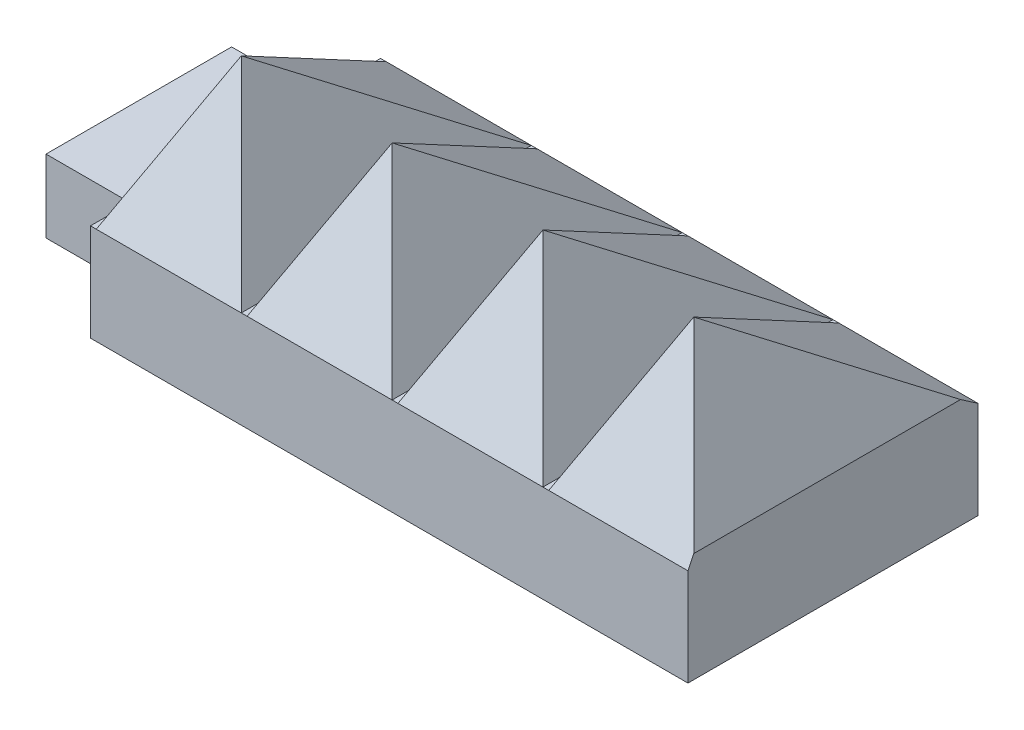
from build123d import *

# Parameters (mm, degrees)
SKETCH1_W           = 19.05
SKETCH1_H           = 19.05
BOSS_EXTRUDE2_DEPTH = 6.35
SKETCH8_W           = 217.17
SKETCH8_H           = 38.1
BOSS_EXTRUDE4_DEPTH = 6.35
SKETCH8_5_W         = 217.17
SKETCH8_5_H         = 38.1
BOSS_EXTRUDE5_DEPTH = 6.4262
SKETCH9_W           = 19.05
SKETCH9_H           = 38.1
LPATTERN3_COUNT     = 11
LPATTERN3_PITCH     = 19.812
SKETCH15_R          = 12.192
BOSS_EXTRUDE6_DEPTH = 6.35
SKETCH16_W          = 38.1
SKETCH16_H          = 22.073264639
CUT_EXTRUDE1_DEPTH  = 3.302
SKETCH17_W          = 61.644203732
SKETCH17_H          = 46.422477749
CUT_EXTRUDE2_DEPTH  = 137.922
SKETCH18_W          = 24.384
SKETCH18_H          = 9.5504
BOSS_EXTRUDE7_DEPTH = 12.7


with BuildPart() as part:
    # Sketch1 → Boss-Extrude2 (new body)
    with BuildSketch(Plane(origin=(0, 0, 0), x_dir=(1, 0, 0), z_dir=(0, 1, 0))):
        with Locations((9.525, -9.525)):
            Rectangle(SKETCH1_W, SKETCH1_H)
    extrude(amount=BOSS_EXTRUDE2_DEPTH)

    # Sketch8 → Boss-Extrude4 (add)
    with BuildSketch(Plane(origin=(0, 0, 0), x_dir=(1, 0, 0), z_dir=(0, 1, 0))):
        with Locations((108.585, -9.525)):
            Rectangle(SKETCH8_W, SKETCH8_H)
    extrude(amount=BOSS_EXTRUDE4_DEPTH)

    # Sketch8_5 → Boss-Extrude5 (add)
    with BuildSketch(Plane(origin=(0, 0, 0), x_dir=(1, 0, 0), z_dir=(0, 1, 0))):
        with Locations((108.585, -9.525)):
            Rectangle(SKETCH8_5_W, SKETCH8_5_H)
    extrude(amount=-BOSS_EXTRUDE5_DEPTH)

    # Sketch9 → Loft3 section 0
    with BuildSketch(Plane(origin=(0, 6.35, 0), x_dir=(1, 0, 0), z_dir=(0, 1, 0)), mode=Mode.PRIVATE) as loft3_s0:
        with Locations((9.525, -9.525)):
            Rectangle(SKETCH9_W, SKETCH9_H)
    loft3 = loft([loft3_s0.sketch, Vertex(9.525, 26.0731, 19.05)])

    # LPattern3: Loft3 ×11
    with Locations(*[(i * LPATTERN3_PITCH, 0, 0) for i in range(1, LPATTERN3_COUNT)]):
        add(loft3)

    # Sketch15 → Boss-Extrude6 (add)
    with BuildSketch(Plane.XZ.offset(6.4262)):
        with Locations((179.07, 9.525)):
            Circle(SKETCH15_R)
        with Locations((38.1, 9.525)):
            Circle(SKETCH15_R)
        with Locations((108.585, 9.525)):
            Circle(SKETCH15_R)
    extrude(amount=BOSS_EXTRUDE6_DEPTH)

    # Sketch16 → Cut-Extrude1 (cut)
    with BuildSketch(Plane(origin=(219.71, 0, 0), x_dir=(0, 0, -1), z_dir=(1, 0, 0))):
        with Locations((-9.525, 4.61043232)):
            Rectangle(SKETCH16_W, SKETCH16_H)
    extrude(amount=-CUT_EXTRUDE1_DEPTH, mode=Mode.SUBTRACT)

    # Sketch17 → Cut-Extrude2 (cut)
    with BuildSketch(Plane.ZY):
        with Locations((9.467504242, 6.577579821)):
            Rectangle(SKETCH17_W, SKETCH17_H)
    extrude(amount=-CUT_EXTRUDE2_DEPTH, mode=Mode.SUBTRACT)

    # Sketch18 → Boss-Extrude7 (add)
    with BuildSketch(Plane.ZY.offset(-137.922)):
        with Locations((9.525, -0.0381)):
            Rectangle(SKETCH18_W, SKETCH18_H)
    extrude(amount=BOSS_EXTRUDE7_DEPTH)


solid = part.part
